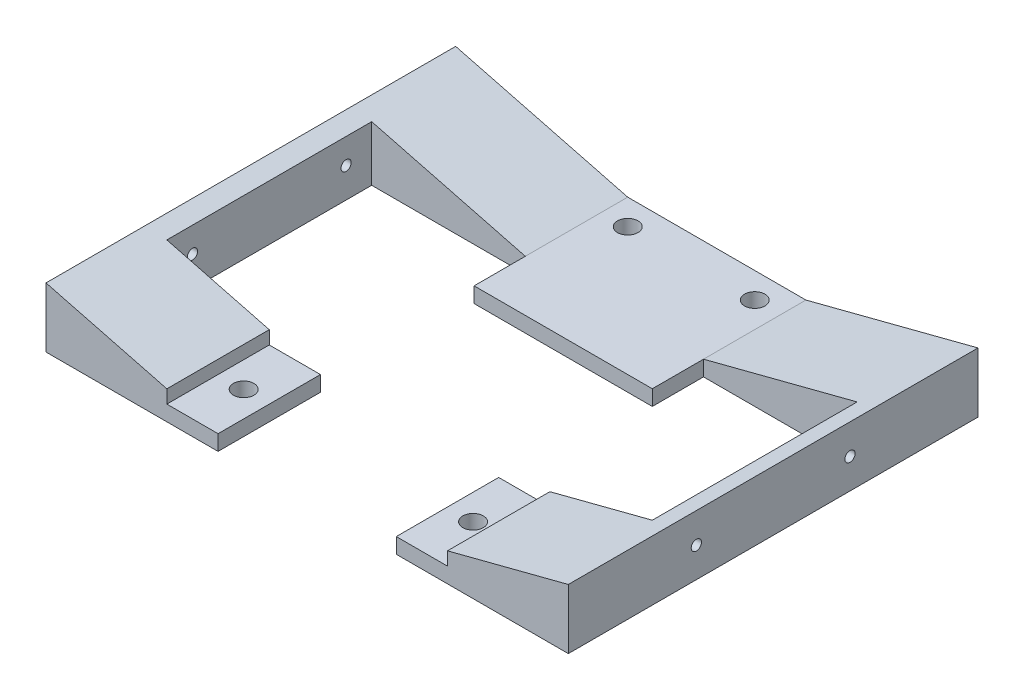
from build123d import *

# Parameters (mm, degrees)
SKETCH1_W                = 259.08
SKETCH1_H                = 298.45
BOSS_EXTRUDE3_DEPTH      = 14.732
SKETCH2_W                = 259.08
SKETCH2_H                = 298.45
BOSS_EXTRUDE4_DEPTH      = 22.098
SKETCH4_OUTSIDE_W        = 379.836
SKETCH4_OUTSIDE_H        = 118.216
CUT_EXTRUDE2_DEPTH       = 259.08
SKETCH6_OUTSIDE_W        = 340.466
SKETCH6_OUTSIDE_H        = 118.216
CUT_EXTRUDE4_DEPTH       = 298.45
BOSS_EXTRUDE6_DEPTH      = 101.6
BOSS_EXTRUDE6_DEPTH_BACK = 101.6
SKETCH8_W                = 88.392
SKETCH8_H                = 7.62
CUT_EXTRUDE5_DEPTH       = 127
CUT_EXTRUDE7_DEPTH       = 50.8
CUT_EXTRUDE7_DEPTH_BACK  = 50.8
SKETCH15_W               = 25.4
SKETCH15_H               = 6.576785714
CUT_EXTRUDE8_DEPTH       = 53.086
SKETCH16_W               = 25.4
SKETCH16_H               = 6.576785714
CUT_EXTRUDE9_DEPTH       = 53.086
SKETCH17_R               = 5.08
CUT_EXTRUDE10_DEPTH      = 8.62
SKETCH18_R               = 2.54
CUT_EXTRUDE11_DEPTH      = 260.08
SKETCH19_R               = 5.08
CUT_EXTRUDE12_DEPTH      = 8.62
SKETCH21_R               = 5.08
CUT_EXTRUDE13_DEPTH      = 8.62


with BuildPart() as part:
    # Sketch1 → Boss-Extrude3 (new body)
    with BuildSketch(Plane(origin=(0, 0, 0), x_dir=(1, 0, 0), z_dir=(0, 1, 0))):
        Rectangle(SKETCH1_W, SKETCH1_H)
    extrude(amount=BOSS_EXTRUDE3_DEPTH)

    # Sketch2 → Boss-Extrude4 (add)
    with BuildSketch(Plane.XZ):
        Rectangle(SKETCH2_W, SKETCH2_H)
    extrude(amount=BOSS_EXTRUDE4_DEPTH)

    # Sketch4 outside → Cut-Extrude2 (cut)
    with BuildSketch(Plane(origin=(129.54, 0, 0), x_dir=(0, 0, -1), z_dir=(1, 0, 0))):
        with Locations((0, -3.683)):
            Rectangle(SKETCH4_OUTSIDE_W, SKETCH4_OUTSIDE_H)
        Polygon((0, -22.098), (-149.225, 0), (-149.225, 14.732), (149.225, 14.732), (149.225, 0), align=None, mode=Mode.SUBTRACT)
    extrude(amount=-CUT_EXTRUDE2_DEPTH, mode=Mode.SUBTRACT)

    # Sketch6 outside → Cut-Extrude4 (cut)
    with BuildSketch(Plane.XY.offset(149.225)):
        with Locations((0, -3.683)):
            Rectangle(SKETCH6_OUTSIDE_W, SKETCH6_OUTSIDE_H)
        Polygon((-44.196, -22.098), (44.196, -22.098), (129.54, 0), (129.54, 14.732), (-129.54, 14.732), (-129.54, 0), align=None, mode=Mode.SUBTRACT)
    extrude(amount=-CUT_EXTRUDE4_DEPTH, mode=Mode.SUBTRACT)


with BuildPart() as body_2:
    # Sketch7 → Boss-Extrude6 (new body, two sides)
    with BuildSketch(Plane.XY) as boss_extrude6_sk:
        Polygon((44.196, -27.178), (129.54, -5.08), (129.54, -34.798), (-129.54, -34.798), (-129.54, -5.08), (-44.196, -27.178), align=None)
    extrude(amount=BOSS_EXTRUDE6_DEPTH)
    extrude(boss_extrude6_sk.sketch, amount=-BOSS_EXTRUDE6_DEPTH_BACK)

    # Sketch8 → Cut-Extrude5 (cut)
    with BuildSketch(Plane.XY.offset(101.6)):
        with Locations((0, -30.988)):
            Rectangle(SKETCH8_W, SKETCH8_H)
    extrude(amount=-CUT_EXTRUDE5_DEPTH, mode=Mode.SUBTRACT)

    # Sketch10 → Cut-Extrude7 (cut, two sides)
    with BuildSketch(Plane.XY) as cut_extrude7_sk:
        Polygon((-44.196, -27.178), (-120.396, -7.447642857), (-120.396, -34.798), (-44.196, -34.798), align=None)
        Polygon((120.396, -7.447642857), (44.196, -27.178), (44.196, -34.798), (120.396, -34.798), align=None)
    extrude(amount=CUT_EXTRUDE7_DEPTH, mode=Mode.SUBTRACT)
    extrude(cut_extrude7_sk.sketch, amount=-CUT_EXTRUDE7_DEPTH_BACK, mode=Mode.SUBTRACT)

    # Sketch15 → Cut-Extrude8 (cut)
    with BuildSketch(Plane.XY.offset(101.6)):
        with Locations((56.896, -23.889607143)):
            Rectangle(SKETCH15_W, SKETCH15_H)
    extrude(amount=-CUT_EXTRUDE8_DEPTH, mode=Mode.SUBTRACT)

    # Sketch16 → Cut-Extrude9 (cut)
    with BuildSketch(Plane.XY.offset(101.6)):
        with Locations((-56.896, -23.889607143)):
            Rectangle(SKETCH16_W, SKETCH16_H)
    extrude(amount=-CUT_EXTRUDE9_DEPTH, mode=Mode.SUBTRACT)

    # Sketch17 → Cut-Extrude10 (cut, through all)
    with BuildSketch(Plane(origin=(0, -27.178, 0), x_dir=(1, 0, 0), z_dir=(0, 1, 0))):
        with Locations((-31.496, 88.9)):
            Circle(SKETCH17_R)
        with Locations((31.496, 88.9)):
            Circle(SKETCH17_R)
    extrude(amount=-CUT_EXTRUDE10_DEPTH, mode=Mode.SUBTRACT)

    # Sketch18 → Cut-Extrude11 (cut, through all)
    with BuildSketch(Plane.ZY.offset(129.54)):
        with Locations((38.1, -19.939)):
            Circle(SKETCH18_R)
        with Locations((-38.1, -19.939)):
            Circle(SKETCH18_R)
    extrude(amount=-CUT_EXTRUDE11_DEPTH, mode=Mode.SUBTRACT)

    # Sketch19 → Cut-Extrude12 (cut, through all)
    with BuildSketch(Plane(origin=(0, -27.178, 0), x_dir=(1, 0, 0), z_dir=(0, 1, 0))):
        with Locations((-56.896, -76.2)):
            Circle(SKETCH19_R)
    extrude(amount=-CUT_EXTRUDE12_DEPTH, mode=Mode.SUBTRACT)

    # Sketch21 → Cut-Extrude13 (cut, through all)
    with BuildSketch(Plane(origin=(0, -27.178, 0), x_dir=(1, 0, 0), z_dir=(0, 1, 0))):
        with Locations((56.896, -76.2)):
            Circle(SKETCH21_R)
    extrude(amount=-CUT_EXTRUDE13_DEPTH, mode=Mode.SUBTRACT)


solid = body_2.part
